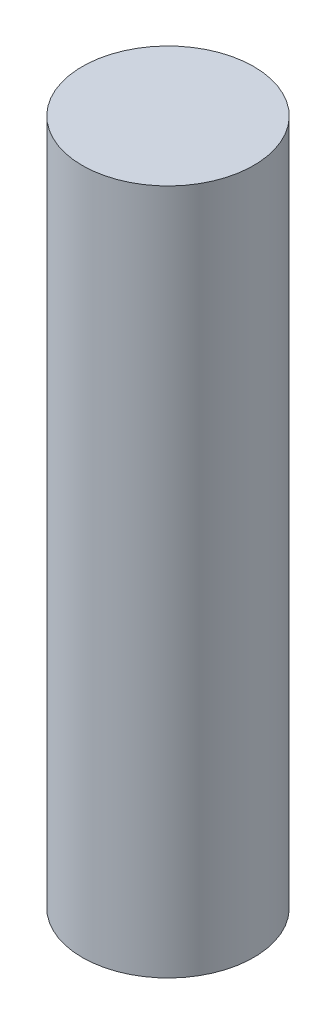
from build123d import *

# Parameters (mm, degrees)
SKETCH2_R           = 5
BOSS_EXTRUDE1_DEPTH = 40


with BuildPart() as part:
    # Sketch2 → Boss-Extrude1 (new body)
    with BuildSketch(Plane(origin=(0, 0, 0), x_dir=(1, 0, 0), z_dir=(0, 1, 0))):
        Circle(SKETCH2_R)
    extrude(amount=BOSS_EXTRUDE1_DEPTH)


solid = part.part
